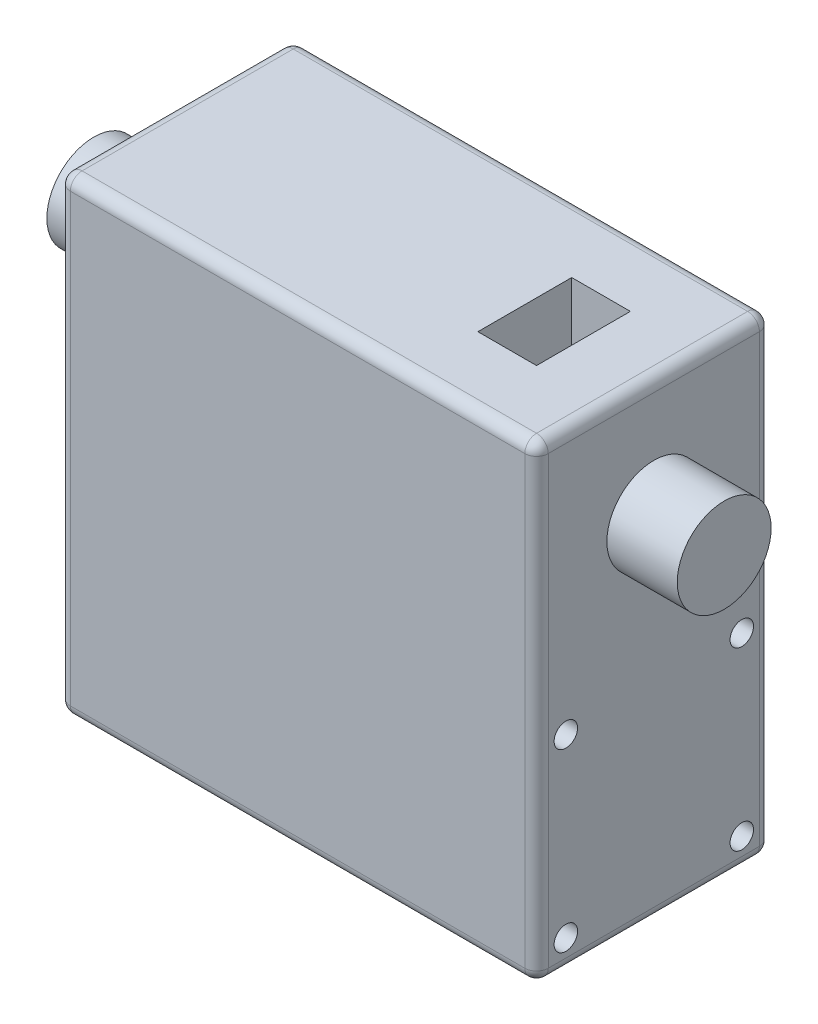
from build123d import *

# Parameters (mm, degrees)
SKETCH1_W           = 40.745918
SKETCH1_H           = 40
BOSS_EXTRUDE1_DEPTH = 20
FILLET1_R           = 1
SKETCH2_R           = 4
BOSS_EXTRUDE2_DEPTH = 6
SKETCH3_W           = 5
SKETCH3_H           = 8
CUT_EXTRUDE1_DEPTH  = 5
SKETCH4_R           = 4
BOSS_EXTRUDE3_DEPTH = 7
SKETCH5_R           = 1
CUT_EXTRUDE2_DEPTH  = 5
SKETCH6_R           = 1
CUT_EXTRUDE3_DEPTH  = 5


with BuildPart() as part:
    # Sketch1 → Boss-Extrude1 (new body)
    with BuildSketch(Plane.XY):
        with Locations((20.372959, 20)):
            Rectangle(SKETCH1_W, SKETCH1_H)
    extrude(amount=BOSS_EXTRUDE1_DEPTH)

    # Fillet1
    fillet1_edges = [part.edges().sort_by_distance(p)[0] for p in [
        (40.745918, 20, 20),
        (20.372959, 40, 20),
        (0, 20, 20),
        (20.372959, 40, 0),
        (40.745918, 20, 0),
        (20.372959, 0, 0),
        (0, 20, 0),
        (20.372959, 0, 20),
        (0, 40, 10),
        (40.745918, 40, 10),
        (40.745918, 0, 10),
        (0, 0, 10),
    ]]
    fillet(fillet1_edges, radius=FILLET1_R)

    # Sketch2 → Boss-Extrude2 (add)
    with BuildSketch(Plane(origin=(40.745918, 0, 0), x_dir=(0, 0, -1), z_dir=(1, 0, 0))):
        with Locations((-10, 30)):
            Circle(SKETCH2_R)
    extrude(amount=BOSS_EXTRUDE2_DEPTH)

    # Sketch3 → Cut-Extrude1 (cut)
    with BuildSketch(Plane(origin=(0, 40, 0), x_dir=(1, 0, 0), z_dir=(0, 1, 0))):
        with Locations((32.245918, -10)):
            Rectangle(SKETCH3_W, SKETCH3_H)
    extrude(amount=-CUT_EXTRUDE1_DEPTH, mode=Mode.SUBTRACT)

    # Sketch4 → Boss-Extrude3 (add)
    with BuildSketch(Plane.ZY):
        with Locations((10, 30)):
            Circle(SKETCH4_R)
    extrude(amount=BOSS_EXTRUDE3_DEPTH)

    # Sketch5 → Cut-Extrude2 (cut)
    with BuildSketch(Plane(origin=(40.745918, 0, 0), x_dir=(0, 0, -1), z_dir=(1, 0, 0))):
        with Locations((-17.5, 17.5)):
            Circle(SKETCH5_R)
        with Locations((-2.5, 17.5)):
            Circle(SKETCH5_R)
        with Locations((-2.5, 2.5)):
            Circle(SKETCH5_R)
        with Locations((-17.5, 2.5)):
            Circle(SKETCH5_R)
    extrude(amount=-CUT_EXTRUDE2_DEPTH, mode=Mode.SUBTRACT)

    # Sketch6 → Cut-Extrude3 (cut)
    with BuildSketch(Plane.ZY):
        with Locations((17, 10)):
            Circle(SKETCH6_R)
        with Locations((10, 3)):
            Circle(SKETCH6_R)
        with Locations((3, 10)):
            Circle(SKETCH6_R)
    extrude(amount=-CUT_EXTRUDE3_DEPTH, mode=Mode.SUBTRACT)


solid = part.part
